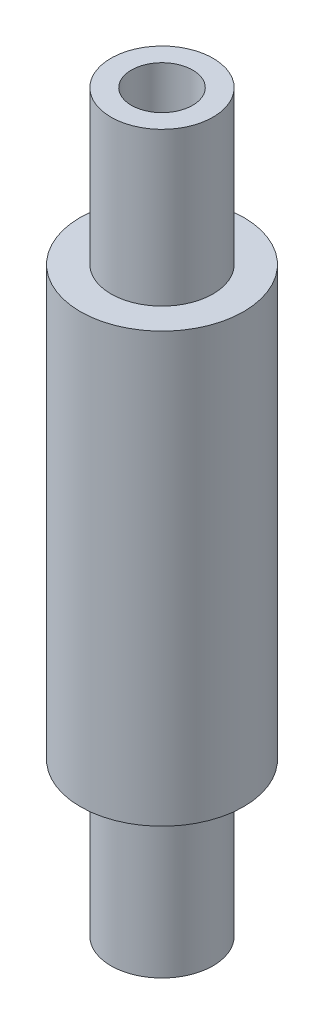
from build123d import *

# Parameters (mm, degrees)
SKETCH1_R           = 4
SKETCH1_R_2         = 1.25
BOSS_EXTRUDE1_DEPTH = 21
SKETCH2_R           = 2.5
BOSS_EXTRUDE2_DEPTH = 7.5
SKETCH3_R           = 2.5
BOSS_EXTRUDE3_DEPTH = 7.5
SKETCH4_R           = 1.5
CUT_EXTRUDE1_DEPTH  = 37


with BuildPart() as part:
    # Sketch1 → Boss-Extrude1 (new body)
    with BuildSketch(Plane(origin=(0, 0, 0), x_dir=(1, 0, 0), z_dir=(0, 1, 0))):
        Circle(SKETCH1_R)
        Circle(SKETCH1_R_2, mode=Mode.SUBTRACT)
    extrude(amount=BOSS_EXTRUDE1_DEPTH)

    # Sketch2 → Boss-Extrude2 (add)
    with BuildSketch(Plane.XZ):
        Circle(SKETCH2_R)
    extrude(amount=BOSS_EXTRUDE2_DEPTH)

    # Sketch3 → Boss-Extrude3 (add)
    with BuildSketch(Plane(origin=(0, 21, 0), x_dir=(1, 0, 0), z_dir=(0, 1, 0))):
        Circle(SKETCH3_R)
    extrude(amount=BOSS_EXTRUDE3_DEPTH)

    # Sketch4 → Cut-Extrude1 (cut, through all)
    with BuildSketch(Plane(origin=(0, 28.5, 0), x_dir=(1, 0, 0), z_dir=(0, 1, 0))):
        Circle(SKETCH4_R)
    extrude(amount=-CUT_EXTRUDE1_DEPTH, mode=Mode.SUBTRACT)


solid = part.part
